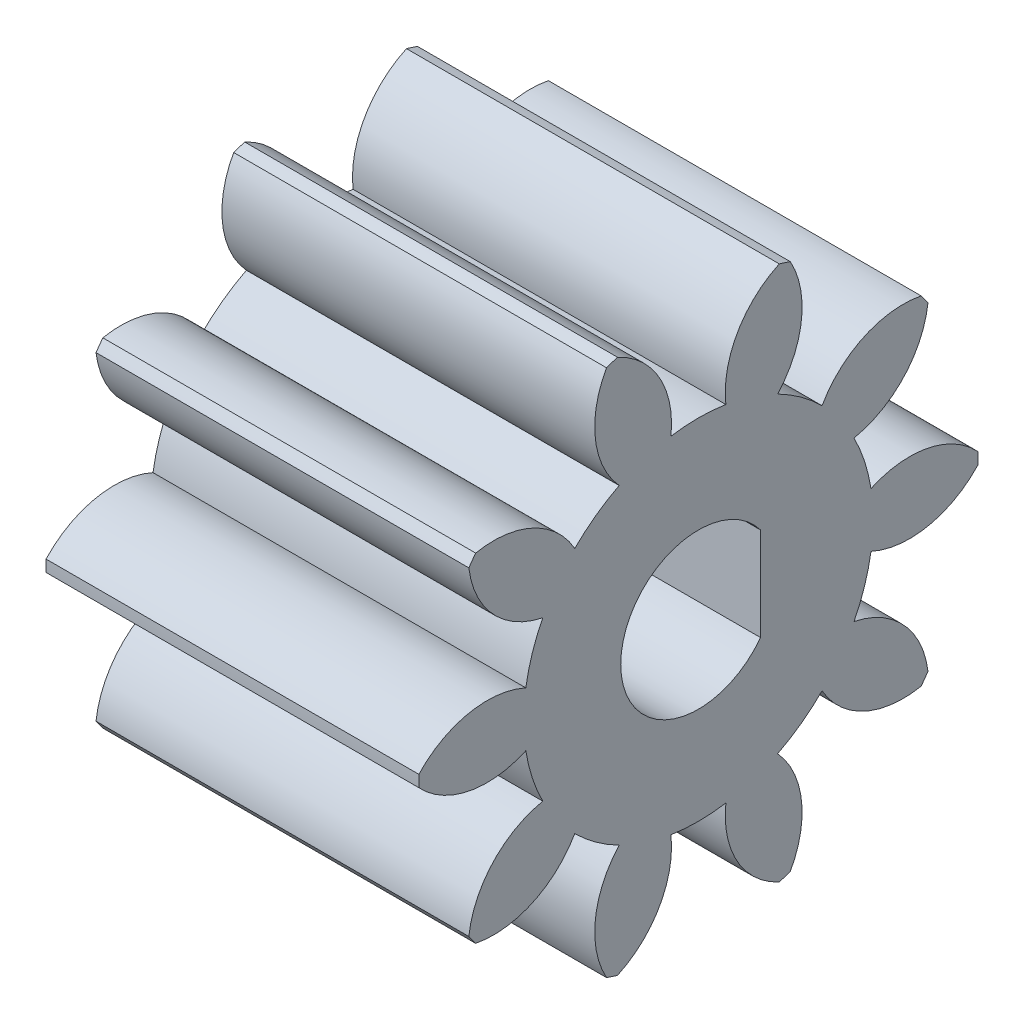
from build123d import *

# Parameters (mm, degrees)
BASPROSKE_W        = 12
BASPROSKE_H        = 9
TOOTHCUT_DEPTH     = 18.492855685
TEETHCUTS_COUNT    = 10
TEETHCUTS_ANGLE    = 324
BORSKE_R           = 2
BORE_DEPTH         = 50.0000508
CUT_EXTRUDE1_DEPTH = 18


with BuildPart() as part:
    # BasProSke → Base-Revolve (revolve)
    with BuildSketch(Plane(origin=(0, 0, 0), x_dir=(1, 0, 0), z_dir=(0, 1, 0)), mode=Mode.PRIVATE) as base_revolve_sk:
        with Locations((6, 4.5)):
            Rectangle(BASPROSKE_W, BASPROSKE_H)
    revolve(base_revolve_sk.sketch.rotate(Axis((-10, 0, 0), (1, 0, 0)), 180), axis=Axis((-10, 0, 0), (1, 0, 0)))

    # TooCutSke → ToothCut (cut, through all)
    with BuildSketch(Plane(origin=(0, 0, 0), x_dir=(0, 0, -1), z_dir=(1, 0, 0))):
        with BuildLine():
            ThreePointArc((0.883878355, 5.554109745), (0, 5.624), (-0.883878355, 5.554109745))
            ThreePointArc((-0.883878355, 5.554109745), (-1.258245767, 7.379188248), (-2.637816971, 8.631324741))
            ThreePointArc((-2.637816971, 8.631324741), (0, 9.0254), (2.637816971, 8.631324741))
            ThreePointArc((2.637816971, 8.631324741), (1.258245767, 7.379188248), (0.883878355, 5.554109745))
        make_face()
    toothcut = extrude(amount=TOOTHCUT_DEPTH, mode=Mode.SUBTRACT)

    # TeethCuts: ToothCut ×10 about axis
    teethcuts_axis = Axis((-10, 0, 0), (1, 0, 0))
    for i in range(1, TEETHCUTS_COUNT):
        add(toothcut.rotate(teethcuts_axis, i * TEETHCUTS_ANGLE / (TEETHCUTS_COUNT - 1)), mode=Mode.SUBTRACT)

    # BorSke → Bore (cut, symmetric)
    with BuildSketch(Plane(origin=(0, 0, 0), x_dir=(0, 0, -1), z_dir=(1, 0, 0))):
        with Locations(Location((0, 0, 0), (0, 0, 180))):
            Circle(BORSKE_R)
    extrude(amount=BORE_DEPTH, both=True, mode=Mode.SUBTRACT)

    # Sketch1 → Cut-Extrude1 (cut)
    with BuildSketch(Plane(origin=(12, 0, 0), x_dir=(0, 0, -1), z_dir=(1, 0, 0))):
        with BuildLine():
            Line((2, 1.5), (2, -1.5))
            ThreePointArc((2, -1.5), (-2.5, 0), (2, 1.5))
        make_face()
    extrude(amount=-CUT_EXTRUDE1_DEPTH, mode=Mode.SUBTRACT)


solid = part.part
